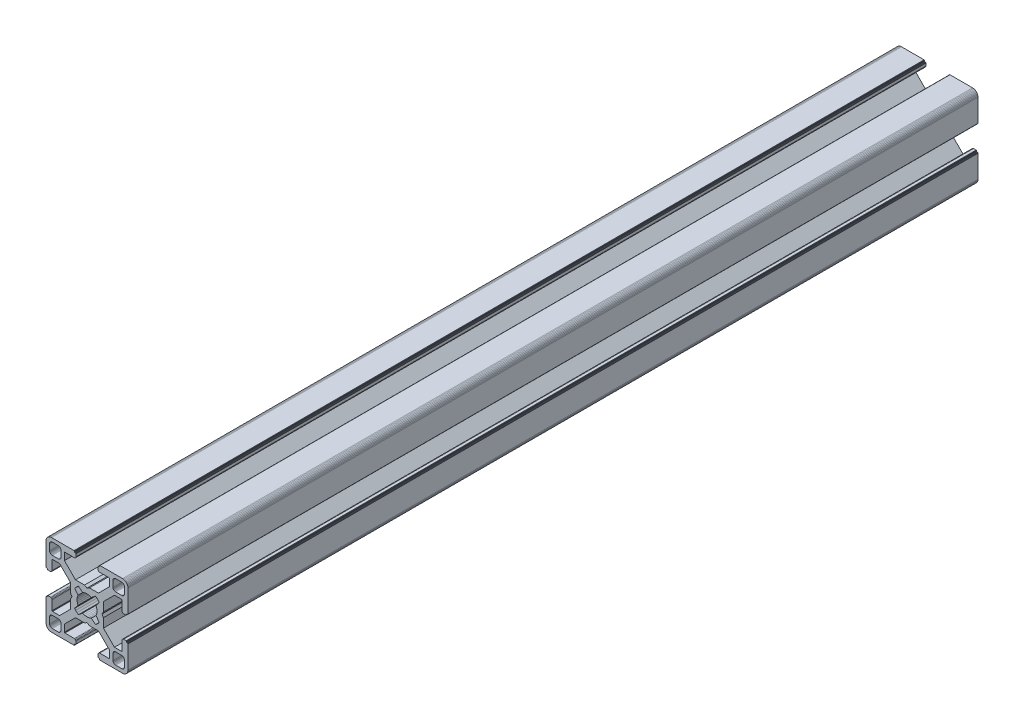
from build123d import *

# Parameters (mm, degrees)
BOSS_EXTRUDE1_DEPTH = 311


with BuildPart() as part:
    # Sketch1 → Boss-Extrude1 (new body)
    with BuildSketch(Plane.XY):
        Polygon((28.34729664, 29.969613999), (28.000000864, 29.999999329), (19.750000909, 29.999999329), (19.715268165, 29.996961355), (19.681595266, 29.987938702), (19.649999216, 29.973205179), (19.621443003, 29.953207821), (19.596790895, 29.928557575), (19.576793537, 29.899999499), (19.562061876, 29.868405312), (19.55303736, 29.834728688), (19.549999386, 29.799999669), (19.549999386, 29.699999839), (19.546961412, 29.665268958), (19.537936896, 29.631596059), (19.523203373, 29.599998146), (19.503207877, 29.571441934), (19.478557631, 29.546789825), (19.449999556, 29.526794329), (19.418403506, 29.512060806), (19.384728745, 29.503038153), (19.349999726, 29.500000179), (19.249999896, 29.500000179), (19.215267517, 29.496958527), (19.181592755, 29.487935874), (19.149996706, 29.47320235), (19.12143863, 29.453206855), (19.096788384, 29.428554746), (19.076791026, 29.399996671), (19.062057503, 29.368402484), (19.05303485, 29.334725859), (19.049996876, 29.299998703), (19.049996876, 28.39999837), (19.059110798, 28.29580945), (19.08618062, 28.194785165), (19.13038119, 28.099997016), (19.190369539, 28.014324653), (19.264324002, 27.94037019), (19.349996366, 27.88038184), (19.444784515, 27.836181271), (19.545806937, 27.809111449), (19.650010894, 27.799984574), (23.050010706, 27.799984574), (23.084741588, 27.7969466), (23.118414487, 27.787923946), (23.150012399, 27.773190423), (23.178568612, 27.753193065), (23.203220721, 27.728542819), (23.223218079, 27.699984744), (23.237949739, 27.668386831), (23.246974255, 27.634713932), (23.25001142, 27.59998608), (23.25001142, 25.049987618), (19.204474482, 20.999982084), (15.900007876, 20.999982084), (15.000008474, 20.48483404), (14.10000814, 20.999982084), (10.795543398, 20.999982084), (7.997342887, 23.801274731), (6.750011387, 25.049984589), (6.750011387, 27.599983051), (6.753049362, 27.634713932), (6.762072946, 27.668386831), (6.776805538, 27.699984744), (6.796801965, 27.728542819), (6.821454073, 27.753193065), (6.850011218, 27.773190423), (6.881607267, 27.787923946), (6.915282029, 27.7969466), (6.950011048, 27.799984574), (10.350011791, 27.799984574), (10.45420071, 27.809098497), (10.555223133, 27.836168318), (10.650011282, 27.880368888), (10.735683645, 27.940357238), (10.809638108, 28.014311701), (10.869626458, 28.099984064), (10.913827027, 28.194772213), (10.940895918, 28.295796498), (10.950010772, 28.399985417), (10.950010772, 29.299985751), (10.946974575, 29.334739239), (10.93795065, 29.368415522), (10.923215933, 29.400009153), (10.903218427, 29.428566473), (10.878566319, 29.45321765), (10.849999264, 29.473204166), (10.818403214, 29.487937689), (10.784728453, 29.496960342), (10.749999434, 29.500000179), (10.649999604, 29.500000179), (10.615270585, 29.503038153), (10.581595823, 29.512060806), (10.549999774, 29.526794329), (10.521441698, 29.546789825), (10.496791452, 29.571441934), (10.476795025, 29.599998146), (10.462061502, 29.631596059), (10.453037918, 29.665268958), (10.449999943, 29.699999839), (10.449999943, 29.799999669), (10.446961969, 29.834728688), (10.437938385, 29.868405312), (10.423205793, 29.899999499), (10.403208435, 29.928557575), (10.378557257, 29.953207821), (10.350000113, 29.973205179), (10.318404064, 29.987938702), (10.284729302, 29.996961355), (10.250000283, 29.999999329), (1.999999397, 29.999999329), (1.652702689, 29.969613999), (1.315958682, 29.879383743), (0.999999233, 29.732050374), (0.714424066, 29.532089829), (0.467910431, 29.285576195), (0.267948955, 28.999999166), (0.120614655, 28.684040532), (0.030384399, 28.34729664), (0, 28.000000864), (0, 19.750000909), (0.003037974, 19.715268165), (0.012061559, 19.681595266), (0.026795082, 19.649999216), (0.046790577, 19.621441141), (0.071442686, 19.596789032), (0.09999983, 19.576793537), (0.13159588, 19.562060013), (0.165270641, 19.55303736), (0.19999966, 19.549999386), (0.299999461, 19.549999386), (0.334728509, 19.546959549), (0.368403242, 19.537936896), (0.399999321, 19.523203373), (0.428556465, 19.503207877), (0.453208573, 19.478555769), (0.473204069, 19.449997693), (0.487937592, 19.418403506), (0.496961176, 19.384728745), (0.499999151, 19.349999726), (0.499999151, 19.249998033), (0.503038056, 19.215269014), (0.512060709, 19.181594253), (0.526794232, 19.150000066), (0.546790194, 19.121441524), (0.571441837, 19.096789882), (0.60000029, 19.076794925), (0.631595686, 19.062061999), (0.665270619, 19.053039982), (0.700000626, 19.050000801), (1.60000096, 19.050000801), (1.704189879, 19.059116587), (1.805213233, 19.086186409), (1.90000045, 19.130385115), (1.985673745, 19.190375328), (2.059627277, 19.264327928), (2.119616325, 19.350002154), (2.163816196, 19.444788441), (2.190886018, 19.545812726), (2.200000872, 19.650001645), (2.200000872, 23.050001457), (2.203039777, 23.084732338), (2.212062431, 23.118405237), (2.226795954, 23.15000315), (2.246792381, 23.178559362), (2.271443558, 23.203211471), (2.300000702, 23.223206967), (2.331596752, 23.23794049), (2.365271513, 23.246965006), (2.400001464, 23.250001117), (4.950000857, 23.250001117), (7.997332093, 20.202670812), (8.995535423, 19.204467788), (8.995535423, 15.900001182), (9.515148227, 15.00000178), (8.995535423, 14.100002378), (8.995535423, 10.795536704), (4.950000857, 6.750002138), (2.400001464, 6.750002138), (2.365271513, 6.753040112), (2.331596752, 6.762063697), (2.300000702, 6.77679722), (2.271443558, 6.796793647), (2.246792381, 6.821444824), (2.226795954, 6.850001968), (2.212062431, 6.881598018), (2.203039777, 6.915272779), (2.200000872, 6.950002729), (2.200000872, 10.350002542), (2.190896812, 10.454174265), (2.16382699, 10.555197618), (2.119627119, 10.649984836), (2.059638071, 10.735658131), (1.985684539, 10.809611663), (1.900011244, 10.869600944), (1.805224027, 10.913800582), (1.704200673, 10.940870404), (1.600011754, 10.949986189), (0.70001142, 10.949986189), (0.665281355, 10.946948596), (0.631606253, 10.937926283), (0.600010578, 10.923193954), (0.571451747, 10.903199537), (0.546799638, 10.87854836), (0.526794232, 10.850000195), (0.512060709, 10.818404146), (0.503038056, 10.784730315), (0.499999151, 10.750000365), (0.499999151, 10.650000535), (0.496961176, 10.615270585), (0.487937592, 10.581596754), (0.473204069, 10.550000705), (0.453208573, 10.521443561), (0.428556465, 10.496791452), (0.399999321, 10.476795956), (0.368403242, 10.462062433), (0.334728509, 10.453038849), (0.299999461, 10.449999943), (0.19999966, 10.449999943), (0.165270641, 10.446961969), (0.13159588, 10.437939316), (0.09999983, 10.423205793), (0.071442686, 10.403209366), (0.046790577, 10.378558189), (0.026795082, 10.350000113), (0.012061559, 10.318404064), (0.003037974, 10.284729302), (0, 10.250000283), (0, 1.999999397), (0.030384399, 1.652702689), (0.120614655, 1.315958682), (0.267948955, 0.999999233), (0.467910431, 0.714424066), (0.714424066, 0.467910431), (0.999999233, 0.267948955), (1.315958682, 0.120614655), (1.652702689, 0.030384399), (1.999999397, 0), (10.250000283, 0), (10.284729302, 0.003037974), (10.318404064, 0.012061559), (10.350000113, 0.026795082), (10.378557257, 0.046790577), (10.403208435, 0.071442686), (10.423205793, 0.09999983), (10.437938385, 0.13159588), (10.446961969, 0.165270641), (10.449999943, 0.19999966), (10.449999943, 0.300000422), (10.453037918, 0.334729441), (10.462061502, 0.368404202), (10.476795025, 0.400000252), (10.496791452, 0.428557396), (10.521441698, 0.453208573), (10.549999774, 0.473205), (10.581595823, 0.487938523), (10.615270585, 0.496961176), (10.649999604, 0.500000082), (10.749999434, 0.500000082), (10.784728453, 0.503038056), (10.818403214, 0.512060709), (10.849999264, 0.526794232), (10.878547894, 0.546800104), (10.903198606, 0.571451747), (10.923194493, 0.6000102), (10.93792742, 0.631606528), (10.946949437, 0.66528146), (10.950010772, 0.699984975), (10.950010772, 1.599985308), (10.940895918, 1.704174228), (10.913827027, 1.805197581), (10.869626458, 1.89998573), (10.809638108, 1.985658094), (10.735683645, 2.059612557), (10.650011282, 2.119600674), (10.555223133, 2.163801476), (10.45420071, 2.190870367), (10.350011791, 2.199985221), (6.950011048, 2.199985221), (6.915282029, 2.203024126), (6.881607267, 2.212046779), (6.850011218, 2.226780302), (6.821454073, 2.246776729), (6.796801965, 2.271427907), (6.776805538, 2.299985982), (6.762072946, 2.331582032), (6.753049362, 2.365256793), (6.750011387, 2.399985812), (6.750011387, 4.949985206), (9.787457566, 7.990785077), (10.795545277, 8.999985833), (14.100010019, 8.999985833), (15.000010353, 9.515133877), (15.900009756, 8.999985833), (19.204476361, 8.999985833), (20.21256413, 7.990786065), (23.25001142, 4.949988235), (23.25001142, 2.399988841), (23.246974255, 2.365256793), (23.237949739, 2.331582032), (23.223218079, 2.299985982), (23.203220721, 2.271427907), (23.178568612, 2.246776729), (23.150012399, 2.226780302), (23.118414487, 2.212046779), (23.084741588, 2.203024126), (23.050010706, 2.199985221), (19.650010894, 2.199985221), (19.545806937, 2.190883319), (19.444784515, 2.163814428), (19.349996366, 2.119613626), (19.264324002, 2.059625509), (19.190369539, 1.985671046), (19.13038119, 1.899998682), (19.08618062, 1.805210533), (19.059110798, 1.70418718), (19.049996876, 1.599998261), (19.049996876, 0.699997927), (19.053035506, 0.665268966), (19.062058795, 0.631594374), (19.076792915, 0.599998603), (19.096790813, 0.571440905), (19.121441524, 0.546790194), (19.149999978, 0.526794306), (19.181596306, 0.51206138), (19.215271238, 0.503039363), (19.249999896, 0.500000082), (19.349999726, 0.500000082), (19.384728745, 0.496961176), (19.418403506, 0.487938523), (19.449999556, 0.473205), (19.478557631, 0.453208573), (19.503207877, 0.428557396), (19.523203373, 0.400000252), (19.537936896, 0.368404202), (19.546961412, 0.334729441), (19.549999386, 0.300000422), (19.549999386, 0.19999966), (19.55303736, 0.165270641), (19.562061876, 0.13159588), (19.576793537, 0.09999983), (19.596789964, 0.071441755), (19.621442072, 0.046789646), (19.649998285, 0.02679415), (19.681594335, 0.012060627), (19.715267234, 0.003037043), (19.750000909, 0), (28.000000864, 0), (28.34729664, 0.030384399), (28.684040532, 0.120614655), (28.999999166, 0.267948955), (29.285576195, 0.467910431), (29.532089829, 0.714424066), (29.732050374, 0.999999233), (29.879383743, 1.315958682), (29.969613999, 1.652702689), (29.999999329, 1.999999397), (29.999999329, 10.250000283), (29.996974806, 10.284715361), (29.987951516, 10.318389952), (29.973217396, 10.349985723), (29.953219499, 10.378543421), (29.928568787, 10.403194133), (29.899999499, 10.423205793), (29.868405312, 10.437939316), (29.834728688, 10.446961969), (29.799999669, 10.449999943), (29.699999839, 10.449999943), (29.664909937, 10.453400043), (29.631233313, 10.462423628), (29.599637263, 10.477157151), (29.57108105, 10.497152646), (29.546427079, 10.521804755), (29.526433446, 10.550361899), (29.511699923, 10.581957949), (29.502675407, 10.615631779), (29.499637433, 10.650361729), (29.499637433, 10.750361559), (29.49697202, 10.784715548), (29.487949367, 10.818389378), (29.473215844, 10.849985428), (29.453220348, 10.878542572), (29.428568239, 10.90319468), (29.400010164, 10.923190176), (29.368415977, 10.937923699), (29.334741215, 10.946947284), (29.300012197, 10.949986189), (28.400011863, 10.949986189), (28.29581215, 10.9408876), (28.194787865, 10.913817778), (28.099999716, 10.86961814), (28.014327352, 10.809628859), (27.940374752, 10.735675327), (27.880384539, 10.650002032), (27.836185833, 10.555214814), (27.809114148, 10.454191461), (27.800000225, 10.350002542), (27.800000225, 6.950002729), (27.796962251, 6.915272779), (27.787939598, 6.881598018), (27.773206075, 6.850001968), (27.753208716, 6.821444824), (27.728558471, 6.796793647), (27.700000395, 6.77679722), (27.668404345, 6.762063697), (27.634729584, 6.753040112), (27.599998702, 6.750002138), (25.05000024, 6.750002138), (23.809199132, 7.99080223), (21.004464477, 10.795534588), (21.004464477, 14.100000262), (20.484851673, 14.999999665), (21.004464477, 15.899999067), (21.004464477, 19.204465672), (25.05000024, 23.250001117), (27.599998702, 23.250001117), (27.634729584, 23.246965006), (27.668404345, 23.23794049), (27.700000395, 23.223206967), (27.728558471, 23.203211471), (27.753208716, 23.178559362), (27.773206075, 23.15000315), (27.787939598, 23.118405237), (27.796962251, 23.084732338), (27.800000225, 23.050001457), (27.800000225, 19.650001645), (27.809114148, 19.545812726), (27.836185833, 19.444788441), (27.880384539, 19.350002154), (27.940370508, 19.264323684), (28.014323108, 19.190371084), (28.099995472, 19.130380872), (28.194783621, 19.086182165), (28.295807906, 19.059112343), (28.400001069, 19.050000801), (29.300001402, 19.050000801), (29.334730421, 19.053040638), (29.368405183, 19.062063291), (29.39999937, 19.076796814), (29.42819671, 19.097149726), (29.452848353, 19.1218023), (29.472843309, 19.150360754), (29.487576235, 19.181955219), (29.496598252, 19.215630151), (29.499637433, 19.250359227), (29.499637433, 19.35036092), (29.502675407, 19.385089939), (29.511699923, 19.4187647), (29.526433446, 19.450358887), (29.546427079, 19.478916963), (29.57108105, 19.503569071), (29.599637263, 19.523564567), (29.631233313, 19.53829809), (29.664909937, 19.547320743), (29.699999839, 19.549999386), (29.799999669, 19.549999386), (29.834728688, 19.55303736), (29.868405312, 19.562060013), (29.899999499, 19.576793537), (29.928557575, 19.596789032), (29.953207821, 19.621441141), (29.973205179, 19.649999216), (29.987938702, 19.681595266), (29.996961355, 19.715268165), (29.999999329, 19.750000909), (29.999999329, 28.000000864), (29.969613999, 28.34729664), (29.879383743, 28.684040532), (29.732050374, 28.999999166), (29.532089829, 29.285576195), (29.285576195, 29.532089829), (28.999999166, 29.732050374), (28.684040532, 29.879383743), align=None)
        Polygon((1.299998723, 25.499999523), (1.299998723, 27.699999511), (1.312309876, 27.856435627), (1.348942518, 28.009016067), (1.408992335, 28.153989464), (1.490981318, 28.287785128), (1.592892222, 28.407108039), (1.71221327, 28.50901708), (1.846008119, 28.591006994), (1.9909814, 28.651056811), (2.143563703, 28.687689453), (2.299998887, 28.699999675), (4.499998875, 28.699999675), (4.656434059, 28.687689453), (4.809016362, 28.651056811), (4.953989759, 28.591006994), (5.087784491, 28.50901708), (5.207106471, 28.407108039), (5.309016444, 28.287785128), (5.391005427, 28.153989464), (5.451056175, 28.009016067), (5.487687886, 27.856435627), (5.499999039, 27.699999511), (5.499999039, 25.499999523), (5.487687886, 25.34356527), (5.451056175, 25.190982968), (5.391005427, 25.04600957), (5.309016444, 24.912213907), (5.207106471, 24.792892858), (5.087784491, 24.690981954), (4.953989759, 24.60899204), (4.809016362, 24.548944086), (4.656434059, 24.512309581), (4.499998875, 24.499999359), (2.299998887, 24.499999359), (2.143563703, 24.512309581), (1.9909814, 24.548944086), (1.846008119, 24.60899204), (1.71221327, 24.690981954), (1.592892222, 24.792892858), (1.490981318, 24.912213907), (1.408992335, 25.04600957), (1.348942518, 25.190982968), (1.312309876, 25.34356527), align=None, mode=Mode.SUBTRACT)
        Polygon((25.34356527, 28.687689453), (25.499999523, 28.699999675), (27.699999511, 28.699999675), (27.856435627, 28.687689453), (28.009017929, 28.651056811), (28.153991327, 28.591006994), (28.28778699, 28.50901708), (28.407108039, 28.407108039), (28.50901708, 28.287785128), (28.591006994, 28.153989464), (28.651056811, 28.009016067), (28.687689453, 27.856435627), (28.700001538, 27.699999511), (28.700001538, 25.499999523), (28.687689453, 25.34356527), (28.651056811, 25.190982968), (28.591006994, 25.04600957), (28.50901708, 24.912213907), (28.407108039, 24.792892858), (28.28778699, 24.690981954), (28.153991327, 24.60899204), (28.009017929, 24.548944086), (27.856435627, 24.512309581), (27.699999511, 24.499999359), (25.499999523, 24.499999359), (25.34356527, 24.512309581), (25.190982968, 24.548944086), (25.04600957, 24.60899204), (24.912215769, 24.690981954), (24.792892858, 24.792892858), (24.690981954, 24.912213907), (24.608993903, 25.04600957), (24.548944086, 25.190982968), (24.512311444, 25.34356527), (24.500001222, 25.499999523), (24.500001222, 27.699999511), (24.512311444, 27.856435627), (24.548944086, 28.009016067), (24.608993903, 28.153989464), (24.690981954, 28.287785128), (24.792892858, 28.407108039), (24.912215769, 28.50901708), (25.04600957, 28.591006994), (25.190982968, 28.651056811), align=None, mode=Mode.SUBTRACT)
        Polygon((14.999999665, 18.649999052), (15.550030395, 18.608318642), (16.087498516, 18.484227359), (16.600128263, 18.280562013), (18.13592948, 19.518401474), (18.644984812, 19.11874488), (19.103571773, 18.662061542), (19.505336881, 18.154669553), (18.280562013, 16.600130126), (18.484227359, 16.087498516), (18.608318642, 15.550030395), (18.649999052, 14.999999665), (18.608318642, 14.449968934), (18.484227359, 13.912500814), (18.280562013, 13.399870135), (19.505336881, 11.845329776), (19.103571773, 11.337937787), (18.644984812, 10.881252587), (18.13592948, 10.481598787), (16.600128263, 11.719437316), (16.087498516, 11.515771039), (15.550030395, 11.391680688), (14.999999665, 11.349999346), (14.449968934, 11.391680688), (13.912500814, 11.515771039), (13.399870135, 11.719437316), (11.864069849, 10.481598787), (11.355013587, 10.881252587), (10.896427557, 11.337937787), (10.494662449, 11.845329776), (11.719438247, 13.399870135), (11.515771039, 13.912500814), (11.391680688, 14.449968934), (11.349999346, 14.999999665), (11.391680688, 15.550030395), (11.515771039, 16.087498516), (11.719438247, 16.600130126), (10.494662449, 18.154669553), (10.896427557, 18.662061542), (11.355013587, 19.11874488), (11.864069849, 19.518401474), (13.399870135, 18.280562013), (13.912500814, 18.484227359), (14.449968934, 18.608318642), align=None, mode=Mode.SUBTRACT)
        Polygon((4.499998875, 1.299999771), (2.299998887, 1.299999771), (2.143563703, 1.312310807), (1.9909814, 1.348942518), (1.846008119, 1.408992335), (1.71221327, 1.490982249), (1.592892222, 1.592892222), (1.490981318, 1.712214202), (1.408992335, 1.846008934), (1.348942518, 1.990982331), (1.312309876, 2.143564634), (1.299998723, 2.299998887), (1.299998723, 4.499999806), (1.312309876, 4.656434059), (1.348942518, 4.809017293), (1.408992335, 4.95399069), (1.490981318, 5.087785423), (1.592892222, 5.207106471), (1.71221327, 5.309017375), (1.846008119, 5.391006358), (1.9909814, 5.451056175), (2.143563703, 5.487688817), (2.299998887, 5.49999997), (4.499998875, 5.49999997), (4.656434059, 5.487688817), (4.809016362, 5.451056175), (4.953989759, 5.391006358), (5.087784491, 5.309017375), (5.207106471, 5.207106471), (5.309016444, 5.087785423), (5.391005427, 4.95399069), (5.451056175, 4.809017293), (5.487687886, 4.656434059), (5.499999039, 4.499999806), (5.499999039, 2.299998887), (5.487687886, 2.143564634), (5.451056175, 1.990982331), (5.391005427, 1.846008934), (5.309016444, 1.712214202), (5.207106471, 1.592892222), (5.087784491, 1.490982249), (4.953989759, 1.408992335), (4.809016362, 1.348942518), (4.656434059, 1.312310807), align=None, mode=Mode.SUBTRACT)
        Polygon((27.699999511, 1.299999771), (25.499999523, 1.299999771), (25.34356527, 1.312310807), (25.190982968, 1.348942518), (25.04600957, 1.408992335), (24.912215769, 1.490982249), (24.792892858, 1.592892222), (24.690981954, 1.712214202), (24.608993903, 1.846008934), (24.548944086, 1.990982331), (24.512311444, 2.143564634), (24.500001222, 2.299998887), (24.500001222, 4.499999806), (24.512311444, 4.656434059), (24.548944086, 4.809017293), (24.608993903, 4.95399069), (24.690981954, 5.087785423), (24.792892858, 5.207106471), (24.912215769, 5.309017375), (25.04600957, 5.391006358), (25.190982968, 5.451056175), (25.34356527, 5.487688817), (25.499999523, 5.49999997), (27.699999511, 5.49999997), (27.856435627, 5.487688817), (28.009017929, 5.451056175), (28.153991327, 5.391006358), (28.28778699, 5.309017375), (28.407108039, 5.207106471), (28.50901708, 5.087785423), (28.591006994, 4.95399069), (28.651056811, 4.809017293), (28.687689453, 4.656434059), (28.700001538, 4.499999806), (28.700001538, 2.299998887), (28.687689453, 2.143564634), (28.651056811, 1.990982331), (28.591006994, 1.846008934), (28.50901708, 1.712214202), (28.407108039, 1.592892222), (28.28778699, 1.490982249), (28.153991327, 1.408992335), (28.009017929, 1.348942518), (27.856435627, 1.312310807), align=None, mode=Mode.SUBTRACT)
    extrude(amount=-BOSS_EXTRUDE1_DEPTH)


solid = part.part
